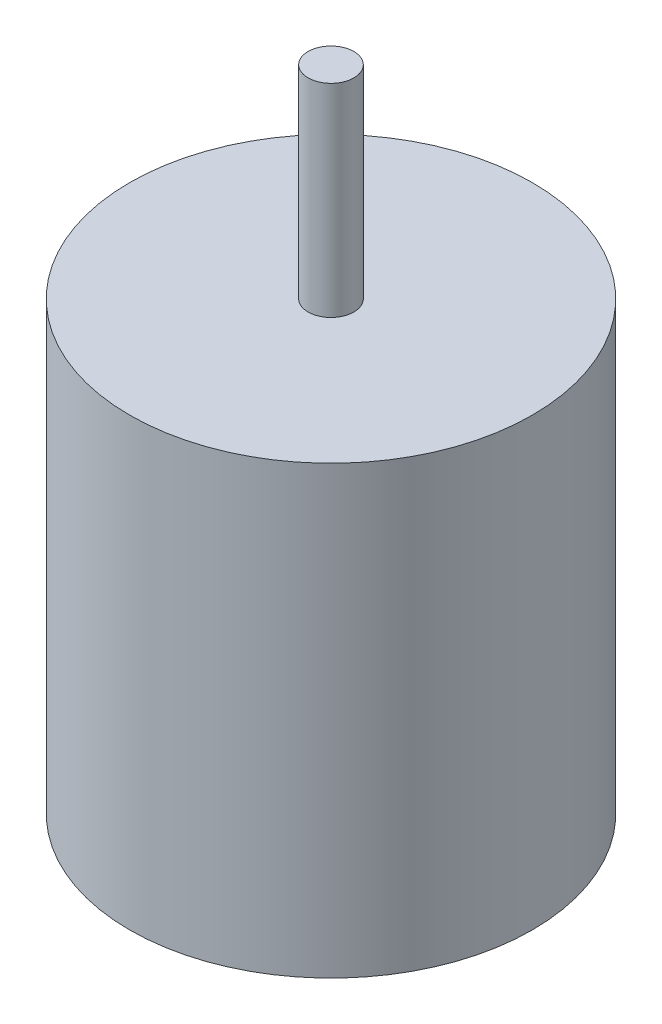
from build123d import *

# Parameters (mm, degrees)
SKETCH1_R           = 14
BOSS_EXTRUDE1_DEPTH = 31
BOSS_EXTRUDE2_START = -31
SKETCH2_R           = 1.59
BOSS_EXTRUDE2_DEPTH = 45.1


with BuildPart() as part:
    # Sketch1 → Boss-Extrude1 (new body)
    with BuildSketch(Plane(origin=(0, 0, 0), x_dir=(1, 0, 0), z_dir=(0, 1, 0))):
        Circle(SKETCH1_R)
    extrude(amount=BOSS_EXTRUDE1_DEPTH)

    # Sketch2 → Boss-Extrude2 (add)
    with BuildSketch(Plane(origin=(0, 31, 0), x_dir=(1, 0, 0), z_dir=(0, 1, 0)).offset(BOSS_EXTRUDE2_START)):
        Circle(SKETCH2_R)
    extrude(amount=BOSS_EXTRUDE2_DEPTH)


solid = part.part
